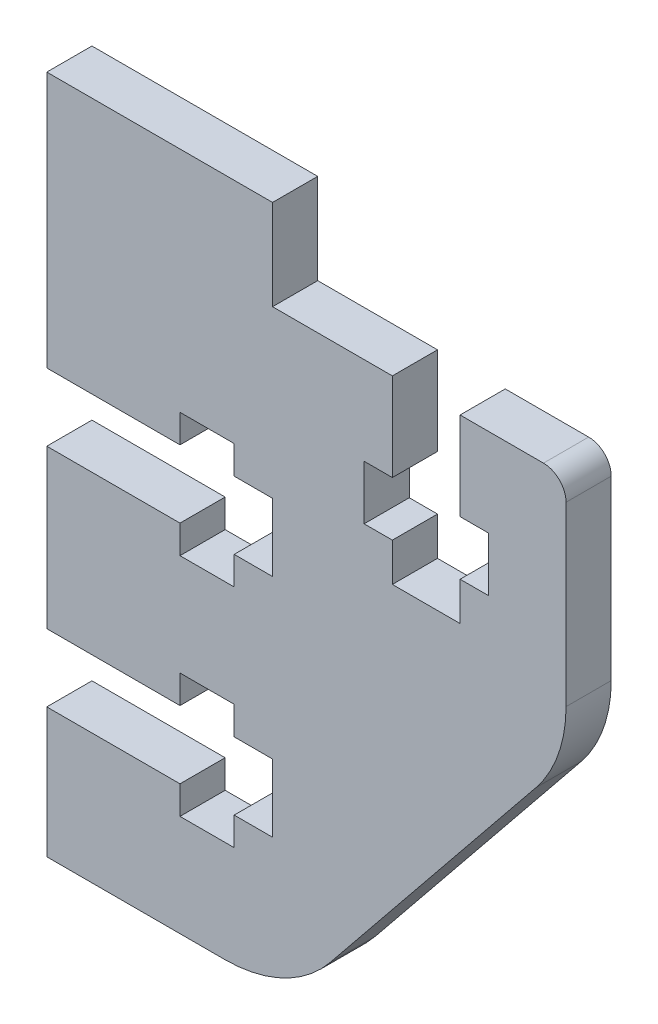
from build123d import *

# Parameters (mm, degrees)
BOSS_EXTRUDE1_DEPTH = 2


with BuildPart() as part:
    # Model → Boss-Extrude1 (new body)
    with BuildSketch(Plane.XY):
        with BuildLine():
            Line((10, 5.75), (8.3, 5.75))
            Line((8.3, 5.75), (8.3, 4.5))
            Line((8.3, 4.5), (5.9, 4.5))
            Line((5.9, 4.5), (5.9, 5.75))
            Line((5.9, 5.75), (0, 5.75))
            Line((0, 5.75), (0, 0))
            Line((0, 0), (7.88848997, 0))
            ThreePointArc((7.88848997, 0), (10.472480827, 0.584929248), (12.552654408, 2.225669584))
            Line((12.552654408, 2.225669584), (21.664164438, 13.485304109))
            ThreePointArc((21.664164438, 13.485304109), (22.656190707, 15.257758734), (23, 17.259634525))
            Line((23, 17.259634525), (23, 25.1))
            ThreePointArc((23, 25.1), (22.707106781, 25.807106781), (22, 26.1))
            Line((22, 26.1), (18.306018336, 26.1))
            Line((18.306018336, 26.1), (18.306018336, 22.2))
            Line((18.306018336, 22.2), (19.556018336, 22.2))
            Line((19.556018336, 22.2), (19.556018336, 19.8))
            Line((19.556018336, 19.8), (18.306018336, 19.8))
            Line((18.306018336, 19.8), (18.306018336, 18.1))
            Line((18.306018336, 18.1), (15.306018336, 18.1))
            Line((15.306018336, 18.1), (15.306018336, 19.8))
            Line((15.306018336, 19.8), (14.056018336, 19.8))
            Line((14.056018336, 19.8), (14.056018336, 22.2))
            Line((14.056018336, 22.2), (15.306018336, 22.2))
            Line((15.306018336, 22.2), (15.306018336, 26.1))
            Line((15.306018336, 26.1), (10, 26.1))
            Line((10, 26.1), (10, 30.1))
            Line((10, 30.1), (0, 30.1))
            Line((0, 30.1), (0, 18.75))
            Line((0, 18.75), (5.9, 18.75))
            Line((5.9, 18.75), (5.9, 20))
            Line((5.9, 20), (8.3, 20))
            Line((8.3, 20), (8.3, 18.75))
            Line((8.3, 18.75), (10, 18.75))
            Line((10, 18.75), (10, 15.75))
            Line((10, 15.75), (8.3, 15.75))
            Line((8.3, 15.75), (8.3, 14.5))
            Line((8.3, 14.5), (5.9, 14.5))
            Line((5.9, 14.5), (5.9, 15.75))
            Line((5.9, 15.75), (0, 15.75))
            Line((0, 15.75), (0, 8.75))
            Line((0, 8.75), (5.9, 8.75))
            Line((5.9, 8.75), (5.9, 10))
            Line((5.9, 10), (8.3, 10))
            Line((8.3, 10), (8.3, 8.75))
            Line((8.3, 8.75), (10, 8.75))
            Line((10, 8.75), (10, 5.75))
        make_face()
    extrude(amount=BOSS_EXTRUDE1_DEPTH)


solid = part.part
